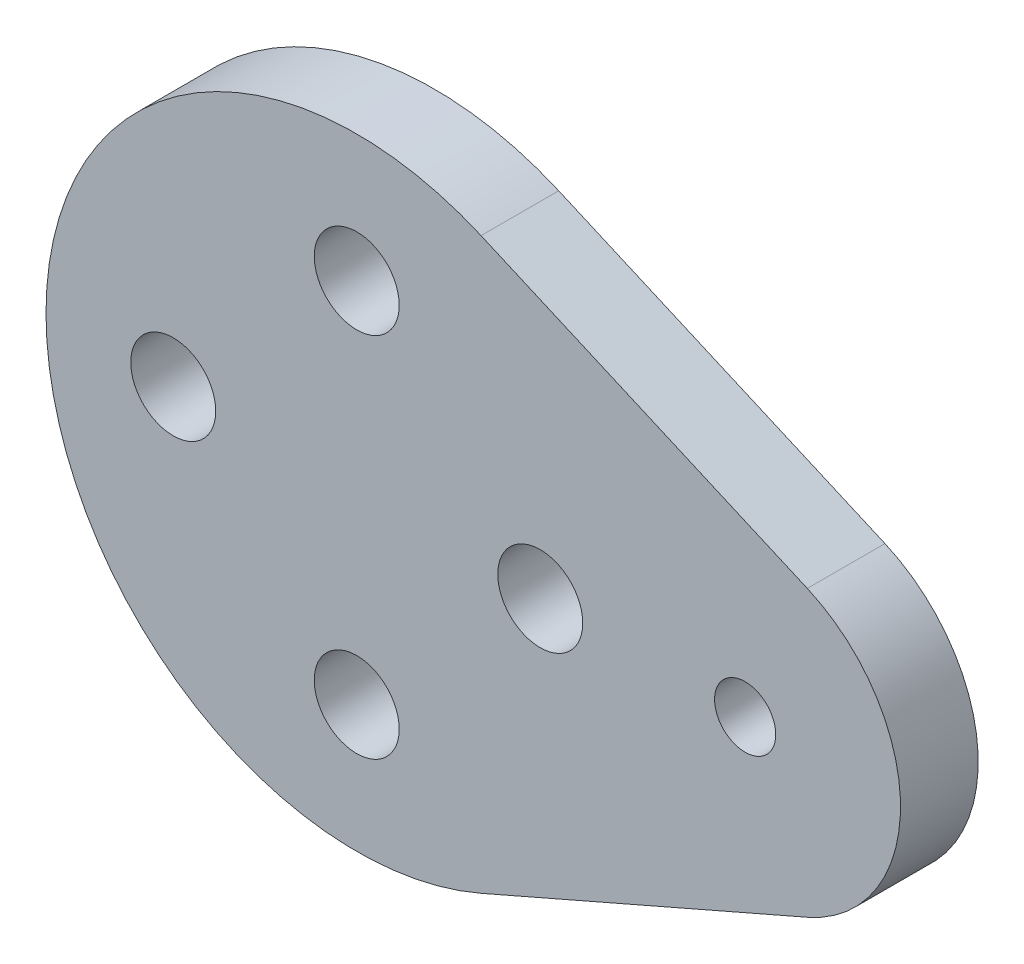
from build123d import *

# Parameters (mm, degrees)
SKETCH1_R           = 1.3890625
SKETCH1_R_2         = 1
BOSS_EXTRUDE1_DEPTH = 2.54


with BuildPart() as part:
    # Sketch1 → Boss-Extrude1 (new body)
    with BuildSketch(Plane.XY):
        with BuildLine():
            Line((4.064, 9.311793812), (14.732, 4.655896906))
            ThreePointArc((14.732, 4.655896906), (17.78, 0), (14.732, -4.655896906))
            Line((14.732, -4.655896906), (4.064, -9.311793812))
            ThreePointArc((4.064, -9.311793812), (-10.16, 0), (4.064, 9.311793812))
        make_face()
        with Locations((0, 6)):
            Circle(SKETCH1_R, mode=Mode.SUBTRACT)
        with Locations((6, 0)):
            Circle(SKETCH1_R, mode=Mode.SUBTRACT)
        with Locations((12.7, 0)):
            Circle(SKETCH1_R_2, mode=Mode.SUBTRACT)
        with Locations((0, -6)):
            Circle(SKETCH1_R, mode=Mode.SUBTRACT)
        with Locations((-6, 0)):
            Circle(SKETCH1_R, mode=Mode.SUBTRACT)
    extrude(amount=BOSS_EXTRUDE1_DEPTH)


solid = part.part
